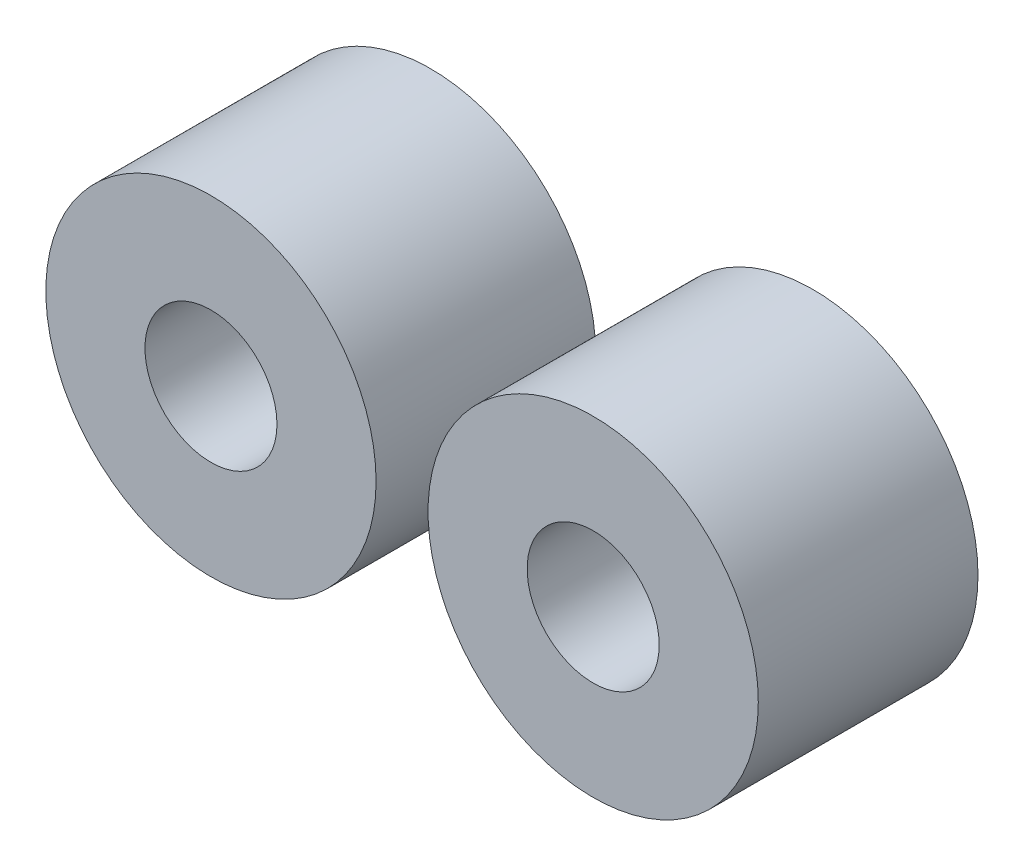
from build123d import *

# Parameters (mm, degrees)
SZKIC1_R                      = 953
SZKIC1_R_2                    = 381
DODANIE_WYCI_GNI_CIE2_DEPTH   = 1268
DODANIE_WYCI_GNI_CIE2_2_DEPTH = 1268


with BuildPart() as part:
    # Szkic1 → Dodanie-wyciągnięcie2 (new body)
    with BuildSketch(Plane.XY):
        Circle(SZKIC1_R)
        Circle(SZKIC1_R_2, mode=Mode.SUBTRACT)
    extrude(amount=DODANIE_WYCI_GNI_CIE2_DEPTH)


with BuildPart() as body_2:
    # Szkic1 → Dodanie-wyci_gni_cie2 2 (new body)
    with BuildSketch(Plane.XY):
        with Locations((2206, 0)):
            Circle(SZKIC1_R)
        with Locations((2206, 0)):
            Circle(SZKIC1_R_2, mode=Mode.SUBTRACT)
    extrude(amount=DODANIE_WYCI_GNI_CIE2_2_DEPTH)


solid = Compound([part.part, body_2.part])
